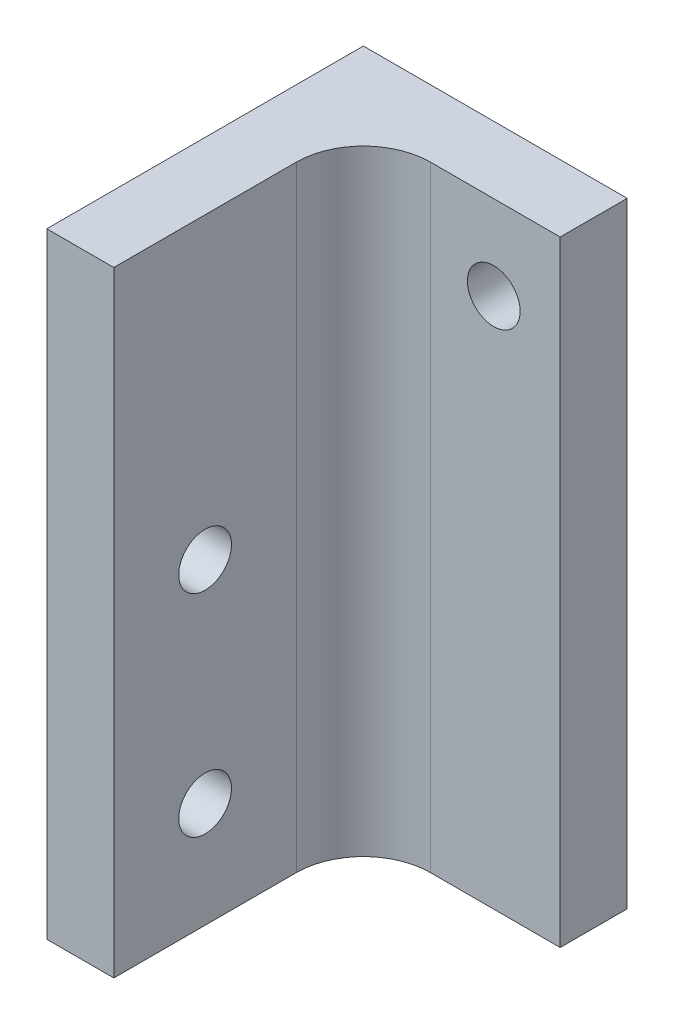
from build123d import *

# Parameters (mm, degrees)
BOSS_EXTRUDE1_DEPTH = 58.31
SKETCH3_R           = 2.5
CUT_EXTRUDE1_DEPTH  = 7.35
SKETCH4_R           = 2.5
CUT_EXTRUDE2_DEPTH  = 7.35


with BuildPart() as part:
    # Sketch2 → Boss-Extrude1 (new body)
    with BuildSketch(Plane(origin=(0, 0, 0), x_dir=(1, 0, 0), z_dir=(0, 1, 0))):
        with BuildLine():
            Line((0, 0), (0, 30))
            Line((0, 30), (25, 30))
            Line((25, 30), (25, 23.65))
            Line((25, 23.65), (12.7, 23.65))
            ThreePointArc((12.7, 23.65), (8.209871939, 21.790128061), (6.35, 17.3))
            Line((6.35, 17.3), (6.35, 0))
            Line((6.35, 0), (0, 0))
        make_face()
    extrude(amount=BOSS_EXTRUDE1_DEPTH)

    # Sketch3 → Cut-Extrude1 (cut, through all)
    with BuildSketch(Plane(origin=(6.35, 0, 0), x_dir=(0, 0, -1), z_dir=(1, 0, 0))):
        with Locations((8.65, 10)):
            Circle(SKETCH3_R)
        with Locations((8.65, 30)):
            Circle(SKETCH3_R)
    extrude(amount=-CUT_EXTRUDE1_DEPTH, mode=Mode.SUBTRACT)

    # Sketch4 → Cut-Extrude2 (cut, through all)
    with BuildSketch(Plane.XY.offset(-23.65)):
        with Locations((18.706720962, 50.31)):
            Circle(SKETCH4_R)
    extrude(amount=-CUT_EXTRUDE2_DEPTH, mode=Mode.SUBTRACT)


solid = part.part
